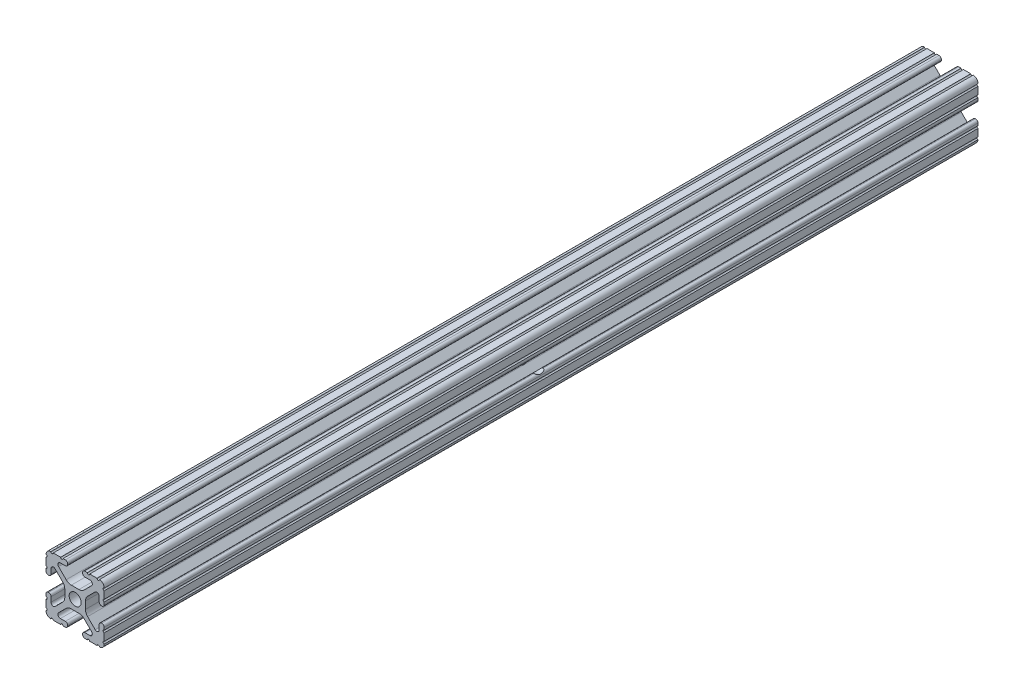
from build123d import *

# Parameters (mm, degrees)
SKETCH1_R           = 2.6035
BOSS_EXTRUDE1_DEPTH = 190.5
SKETCH2_R           = 3.81
CUT_EXTRUDE1_DEPTH  = 25.4


with BuildPart() as part:
    # Sketch1 → Boss-Extrude1 (new body, symmetric)
    with BuildSketch(Plane.XY):
        with BuildLine():
            Line((-7.179650497, -8.645192506), (-3.952270251, -5.423690499))
            ThreePointArc((-3.952270251, -5.423690499), (-2.922936451, -4.736929036), (-1.709253557, -4.4958))
            Line((-1.709253557, -4.4958), (1.709253557, -4.4958))
            ThreePointArc((1.709253557, -4.4958), (2.922936451, -4.736929036), (3.952270251, -5.423690499))
            Line((3.952270251, -5.423690499), (7.179650497, -8.645192506))
            ThreePointArc((7.179650497, -8.645192506), (7.41473083, -9.822813117), (6.416408329, -10.4902))
            Line((6.416408329, -10.4902), (4.287512407, -10.4902))
            ThreePointArc((4.287512407, -10.4902), (3.54574862, -10.79744862), (3.2385, -11.539212407))
            Line((3.2385, -11.539212407), (3.2385, -11.650987593))
            ThreePointArc((3.2385, -11.650987593), (3.54574862, -12.39275138), (4.287512407, -12.7))
            Line((4.287512407, -12.7), (5.317126718, -12.7))
            ThreePointArc((5.317126718, -12.7), (5.825126718, -12.192), (6.333126718, -12.7))
            Line((6.333126718, -12.7), (9.550443118, -12.7))
            ThreePointArc((9.550443118, -12.7), (10.058366869, -12.192000006), (10.566443095, -12.699847501))
            ThreePointArc((10.566443095, -12.699847501), (12.082537762, -12.08250727), (12.699846982, -10.566399977))
            ThreePointArc((12.699846982, -10.566399977), (12.192000006, -10.058323491), (12.7, -9.5504))
            Line((12.7, -9.5504), (12.7, -6.3330836))
            ThreePointArc((12.7, -6.3330836), (12.192, -5.8250836), (12.7, -5.3170836))
            Line((12.7, -5.3170836), (12.7, -4.287469289))
            ThreePointArc((12.7, -4.287469289), (12.39275138, -3.545705502), (11.650987593, -3.238456882))
            Line((11.650987593, -3.238456882), (11.539212407, -3.238456882))
            ThreePointArc((11.539212407, -3.238456882), (10.79744862, -3.545705502), (10.4902, -4.287469289))
            Line((10.4902, -4.287469289), (10.4902, -6.402089023))
            ThreePointArc((10.4902, -6.402089023), (9.856505071, -7.351067942), (8.737131347, -7.129408934))
            Line((8.737131347, -7.129408934), (5.441005833, -3.840816462))
            ThreePointArc((5.441005833, -3.840816462), (4.750877967, -2.809883091), (4.5085, -1.593185507))
            Line((4.5085, -1.593185507), (4.5085, 1.593185507))
            ThreePointArc((4.5085, 1.593185507), (4.750877967, 2.809883091), (5.441005833, 3.840816462))
            Line((5.441005833, 3.840816462), (8.737131347, 7.129408934))
            ThreePointArc((8.737131347, 7.129408934), (9.856505071, 7.351067942), (10.4902, 6.402089023))
            Line((10.4902, 6.402089023), (10.4902, 4.287469289))
            ThreePointArc((10.4902, 4.287469289), (10.79744862, 3.545705502), (11.539212407, 3.238456882))
            Line((11.539212407, 3.238456882), (11.650987593, 3.238456882))
            ThreePointArc((11.650987593, 3.238456882), (12.39275138, 3.545705502), (12.7, 4.287469289))
            Line((12.7, 4.287469289), (12.7, 5.3170836))
            ThreePointArc((12.7, 5.3170836), (12.192, 5.8250836), (12.7, 6.3330836))
            Line((12.7, 6.3330836), (12.7, 9.5504))
            ThreePointArc((12.7, 9.5504), (12.192000006, 10.058323491), (12.699846982, 10.566399977))
            ThreePointArc((12.699846982, 10.566399977), (12.082537762, 12.08250727), (10.566443095, 12.699847501))
            ThreePointArc((10.566443095, 12.699847501), (10.058366869, 12.192000006), (9.550443118, 12.7))
            Line((9.550443118, 12.7), (6.333126718, 12.7))
            ThreePointArc((6.333126718, 12.7), (5.825126718, 12.192), (5.317126718, 12.7))
            Line((5.317126718, 12.7), (4.287512407, 12.7))
            ThreePointArc((4.287512407, 12.7), (3.54574862, 12.39275138), (3.2385, 11.650987593))
            Line((3.2385, 11.650987593), (3.2385, 11.539212407))
            ThreePointArc((3.2385, 11.539212407), (3.54574862, 10.79744862), (4.287512407, 10.4902))
            Line((4.287512407, 10.4902), (6.476788598, 10.4902))
            ThreePointArc((6.476788598, 10.4902), (7.432222385, 9.85140422), (7.207036008, 8.724370562))
            Line((7.207036008, 8.724370562), (3.898272566, 5.423169045))
            ThreePointArc((3.898272566, 5.423169045), (2.869120213, 4.736787962), (1.655778399, 4.4958))
            Line((1.655778399, 4.4958), (-1.655778399, 4.4958))
            ThreePointArc((-1.655778399, 4.4958), (-2.869120213, 4.736787962), (-3.898272566, 5.423169045))
            Line((-3.898272566, 5.423169045), (-7.207036008, 8.724370562))
            ThreePointArc((-7.207036008, 8.724370562), (-7.432222385, 9.85140422), (-6.476788598, 10.4902))
            Line((-6.476788598, 10.4902), (-4.287512407, 10.4902))
            ThreePointArc((-4.287512407, 10.4902), (-3.54574862, 10.79744862), (-3.2385, 11.539212407))
            Line((-3.2385, 11.539212407), (-3.2385, 11.650987593))
            ThreePointArc((-3.2385, 11.650987593), (-3.54574862, 12.39275138), (-4.287512407, 12.7))
            Line((-4.287512407, 12.7), (-5.317126718, 12.7))
            ThreePointArc((-5.317126718, 12.7), (-5.825126718, 12.192), (-6.333126718, 12.7))
            Line((-6.333126718, 12.7), (-9.550443118, 12.7))
            ThreePointArc((-9.550443118, 12.7), (-10.058366869, 12.192000006), (-10.566443095, 12.699847501))
            ThreePointArc((-10.566443095, 12.699847501), (-12.082537762, 12.08250727), (-12.699846982, 10.566399977))
            ThreePointArc((-12.699846982, 10.566399977), (-12.192000006, 10.058323491), (-12.7, 9.5504))
            Line((-12.7, 9.5504), (-12.7, 6.3330836))
            ThreePointArc((-12.7, 6.3330836), (-12.192, 5.8250836), (-12.7, 5.3170836))
            Line((-12.7, 5.3170836), (-12.7, 4.287469289))
            ThreePointArc((-12.7, 4.287469289), (-12.39275138, 3.545705502), (-11.650987593, 3.238456882))
            Line((-11.650987593, 3.238456882), (-11.539212407, 3.238456882))
            ThreePointArc((-11.539212407, 3.238456882), (-10.79744862, 3.545705502), (-10.4902, 4.287469289))
            Line((-10.4902, 4.287469289), (-10.4902, 6.402089023))
            ThreePointArc((-10.4902, 6.402089023), (-9.856505071, 7.351067942), (-8.737131347, 7.129408934))
            Line((-8.737131347, 7.129408934), (-5.441005833, 3.840816462))
            ThreePointArc((-5.441005833, 3.840816462), (-4.750877967, 2.809883091), (-4.5085, 1.593185507))
            Line((-4.5085, 1.593185507), (-4.5085, -1.593185507))
            ThreePointArc((-4.5085, -1.593185507), (-4.750877967, -2.809883091), (-5.441005833, -3.840816462))
            Line((-5.441005833, -3.840816462), (-8.737131347, -7.129408934))
            ThreePointArc((-8.737131347, -7.129408934), (-9.856505071, -7.351067942), (-10.4902, -6.402089023))
            Line((-10.4902, -6.402089023), (-10.4902, -4.287469289))
            ThreePointArc((-10.4902, -4.287469289), (-10.79744862, -3.545705502), (-11.539212407, -3.238456882))
            Line((-11.539212407, -3.238456882), (-11.650987593, -3.238456882))
            ThreePointArc((-11.650987593, -3.238456882), (-12.39275138, -3.545705502), (-12.7, -4.287469289))
            Line((-12.7, -4.287469289), (-12.7, -5.3170836))
            ThreePointArc((-12.7, -5.3170836), (-12.192, -5.8250836), (-12.7, -6.3330836))
            Line((-12.7, -6.3330836), (-12.7, -9.5504))
            ThreePointArc((-12.7, -9.5504), (-12.192000006, -10.058323491), (-12.699846982, -10.566399977))
            ThreePointArc((-12.699846982, -10.566399977), (-12.082537762, -12.08250727), (-10.566443095, -12.699847501))
            ThreePointArc((-10.566443095, -12.699847501), (-10.058366869, -12.192000006), (-9.550443118, -12.7))
            Line((-9.550443118, -12.7), (-6.333126718, -12.7))
            ThreePointArc((-6.333126718, -12.7), (-5.825126718, -12.192), (-5.317126718, -12.7))
            Line((-5.317126718, -12.7), (-4.287512407, -12.7))
            ThreePointArc((-4.287512407, -12.7), (-3.54574862, -12.39275138), (-3.2385, -11.650987593))
            Line((-3.2385, -11.650987593), (-3.2385, -11.539212407))
            ThreePointArc((-3.2385, -11.539212407), (-3.54574862, -10.79744862), (-4.287512407, -10.4902))
            Line((-4.287512407, -10.4902), (-6.416408329, -10.4902))
            ThreePointArc((-6.416408329, -10.4902), (-7.41473083, -9.822813117), (-7.179650497, -8.645192506))
        make_face()
        Circle(SKETCH1_R, mode=Mode.SUBTRACT)
    extrude(amount=BOSS_EXTRUDE1_DEPTH, both=True)

    # Sketch2 → Cut-Extrude1 (cut)
    with BuildSketch(Plane.ZY.offset(12.7)):
        Circle(SKETCH2_R)
    extrude(amount=-CUT_EXTRUDE1_DEPTH, mode=Mode.SUBTRACT)


solid = part.part
